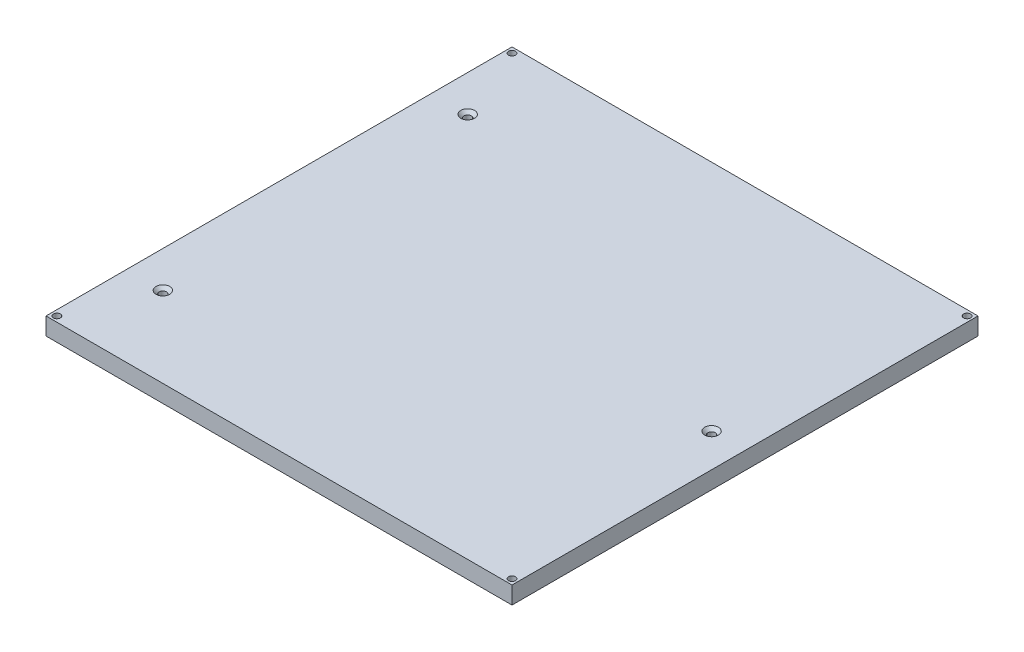
from build123d import *

# Parameters (mm, degrees)
ESQUISSE1_W                                    = 214
ESQUISSE1_H                                    = 214
BOSS_EXTRU_1_DEPTH                             = 8
D_GAGEMENT_M31_D                               = 3.2
FRAISAGE_POUR_VIS_T_TE_FRAIS_E_M31_D           = 3.4
FRAISAGE_POUR_VIS_T_TE_FRAIS_E_M31_CSINK_D     = 6.3
FRAISAGE_POUR_VIS_T_TE_FRAIS_E_M31_CSINK_ANGLE = 90


with BuildPart() as part:
    # Esquisse1 → Boss.-Extru.1 (new body)
    with BuildSketch(Plane(origin=(0, 0, 0), x_dir=(1, 0, 0), z_dir=(0, 1, 0))):
        Rectangle(ESQUISSE1_W, ESQUISSE1_H)
    extrude(amount=BOSS_EXTRU_1_DEPTH)

    # Dégagement M31 (through all)
    with Locations(Plane(origin=(0, 8, 0), x_dir=(1, 0, 0), z_dir=(0, 1, 0))):
        with Locations((-104.5, -104.5), (-104.5, 104.5), (104.5, 104.5), (104.5, -104.5)):
            Hole(D_GAGEMENT_M31_D / 2)

    # Fraisage pour vis à tête fraisée M31 (through all)
    with Locations(Plane(origin=(0, 8, 0), x_dir=(1, 0, 0), z_dir=(0, 1, 0))):
        with Locations((-90.345684211, 70), (-90.345684211, -70), (91.65431579, 0)):
            CounterSinkHole(FRAISAGE_POUR_VIS_T_TE_FRAIS_E_M31_D / 2, FRAISAGE_POUR_VIS_T_TE_FRAIS_E_M31_CSINK_D / 2, counter_sink_angle=FRAISAGE_POUR_VIS_T_TE_FRAIS_E_M31_CSINK_ANGLE)


solid = part.part
